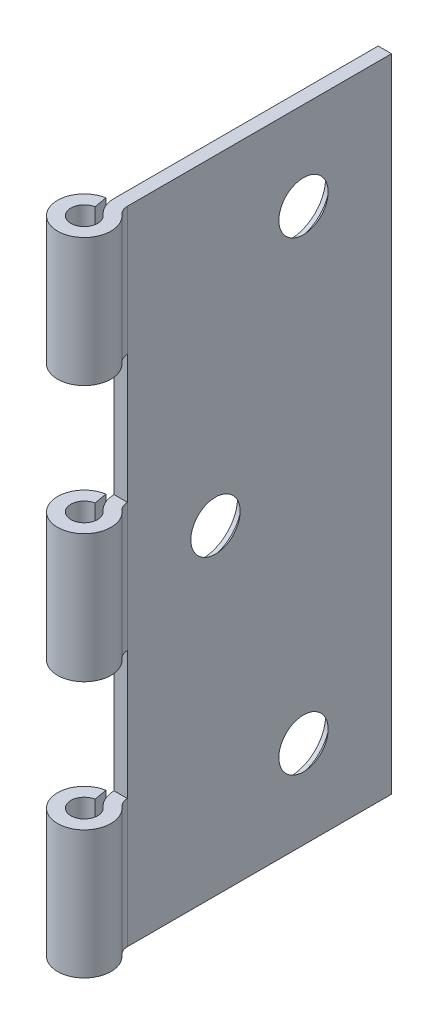
from build123d import *

# Parameters (mm, degrees)
BOSS_EXTRUDE1_DEPTH                       = 38.1
CUT_EXTRUDE1_DEPTH                        = 52.782682916
CUT_EXTRUDE1_DEPTH_BACK                   = 52.782682916
SKETCH3_W                                 = 6.724757914
SKETCH3_H                                 = 15.24
CSK_FOR_8_FLAT_HEAD_MACHINE_SCREW_2_COUNT = 2
CSK_FOR_8_FLAT_HEAD_MACHINE_SCREW_2_PITCH = 29.553945574
CSK_FOR_8_FLAT_HEAD_MACHINE_SCREW_3_COUNT = 2
CSK_FOR_8_FLAT_HEAD_MACHINE_SCREW_3_PITCH = 55.283171943


with BuildPart() as part:
    # Sketch2 → Boss-Extrude1 (new, symmetric)
    with BuildSketch(Plane(origin=(0, 0, 0), x_dir=(1, 0, 0), z_dir=(0, 1, 0))):
        with BuildLine():
            Line((1.5875, 34.925), (0, 34.925))
            Line((0, 34.925), (0, 3.549757914))
            ThreePointArc((0, 3.549757914), (0.2766348, 2.253569592), (1.058333333, 1.183252638))
            ThreePointArc((1.058333333, 1.183252638), (-0.435047689, -1.526725175), (-0.275666482, 1.563382308))
            Line((-0.275666482, 1.563382308), (-0.551332964, 3.126764616))
            ThreePointArc((-0.551332964, 3.126764616), (-0.870095378, -3.053450349), (2.116666667, 2.366505276))
            ThreePointArc((2.116666667, 2.366505276), (1.7258174, 2.901663753), (1.5875, 3.549757914))
            Line((1.5875, 3.549757914), (1.5875, 34.925))
        make_face()
    extrude(amount=BOSS_EXTRUDE1_DEPTH, both=True)

    # Sketch3 → Cut-Extrude1 (cut, two sides: drawn at the far end of the back side and taken through both)
    with BuildSketch(Plane(origin=(0, 0, 0), x_dir=(0, 0, -1), z_dir=(1, 0, 0)).offset(-CUT_EXTRUDE1_DEPTH_BACK)):
        with Locations((0.187378957, 15.24)):
            Rectangle(SKETCH3_W, SKETCH3_H)
        with Locations((0.187378957, -15.24)):
            Rectangle(SKETCH3_W, SKETCH3_H)
    extrude(amount=CUT_EXTRUDE1_DEPTH + CUT_EXTRUDE1_DEPTH_BACK, mode=Mode.SUBTRACT)

    # Sketch4 → CSK for _8 Flat Head Machine Screw _100 (revolve, cut)
    with BuildSketch(Plane(origin=(0, -27.641585971, -24.466585971), x_dir=(0, 0, 1), z_dir=(0, 1, 0))):
        Polygon((0, 0), (0, 3.175), (2.2479, 3.175), (2.2479, 2.159767624), (4.2164, 0.508), (4.2164, 0), align=None)
    csk_for_8_flat_head_machine_screw_100 = revolve(axis=Axis((-6.35, -27.641585971, -24.466585971), (1, 0, 0)), mode=Mode.SUBTRACT)

    # CSK for _8 Flat Head Machine Screw _ 2: CSK for _8 Flat Head Machine Screw _100 ×2
    with Locations(*[Vector(0, 0.9352925788515203, 0.3538753904205162) * (i * CSK_FOR_8_FLAT_HEAD_MACHINE_SCREW_2_PITCH) for i in range(1, CSK_FOR_8_FLAT_HEAD_MACHINE_SCREW_2_COUNT)]):
        add(csk_for_8_flat_head_machine_screw_100, mode=Mode.SUBTRACT)

    # CSK for _8 Flat Head Machine Screw _ 3: CSK for _8 Flat Head Machine Screw _100 ×2
    with Locations(*[(0, i * CSK_FOR_8_FLAT_HEAD_MACHINE_SCREW_3_PITCH, 0) for i in range(1, CSK_FOR_8_FLAT_HEAD_MACHINE_SCREW_3_COUNT)]):
        add(csk_for_8_flat_head_machine_screw_100, mode=Mode.SUBTRACT)


solid = part.part
